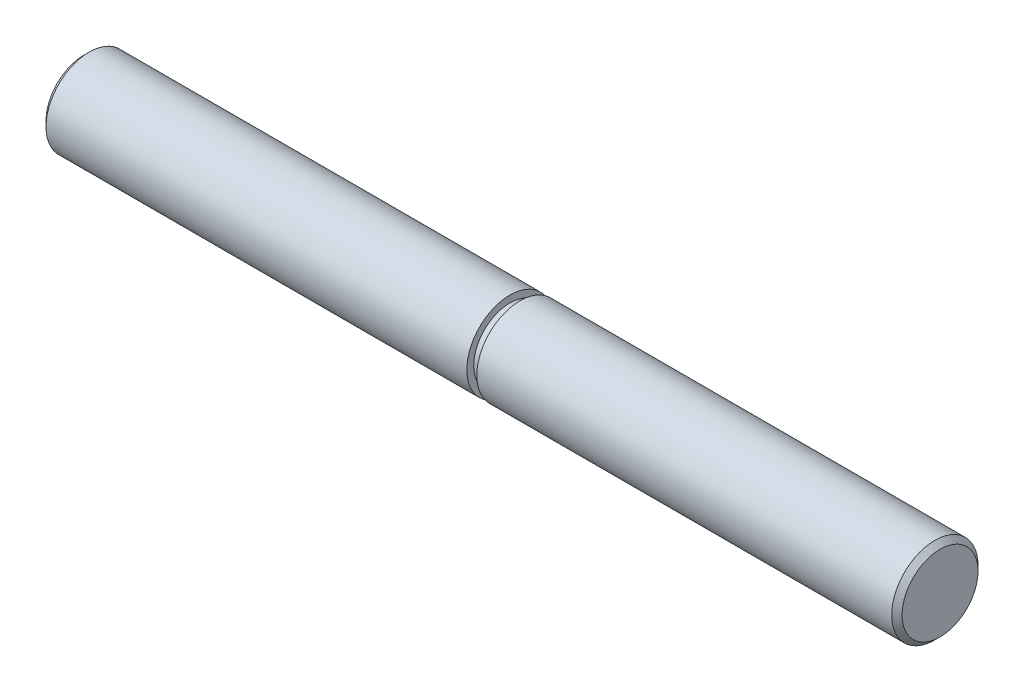
from build123d import *

# Parameters (mm, degrees)
CHAMFER1_SIZE = 0.381


with BuildPart() as part:
    # Sketch2 → Revolve1 (revolve)
    with BuildSketch(Plane.XY):
        Polygon((-31.496, 0), (31.496, 0), (31.496, 3.175), (0.5842, 3.175), (0.5842, 2.667), (-0.1524, 2.667), (-0.1524, 3.175), (-31.496, 3.175), align=None)
    revolve(axis=Axis((-31.496, 0, 0), (-1, 0, 0)))

    # Chamfer1
    chamfer1_edges = [part.edges().sort_by_distance(p)[0] for p in [
        (31.496, -3.175, 0),
        (-31.496, -3.175, 0),
    ]]
    chamfer(chamfer1_edges, length=CHAMFER1_SIZE)


solid = part.part
